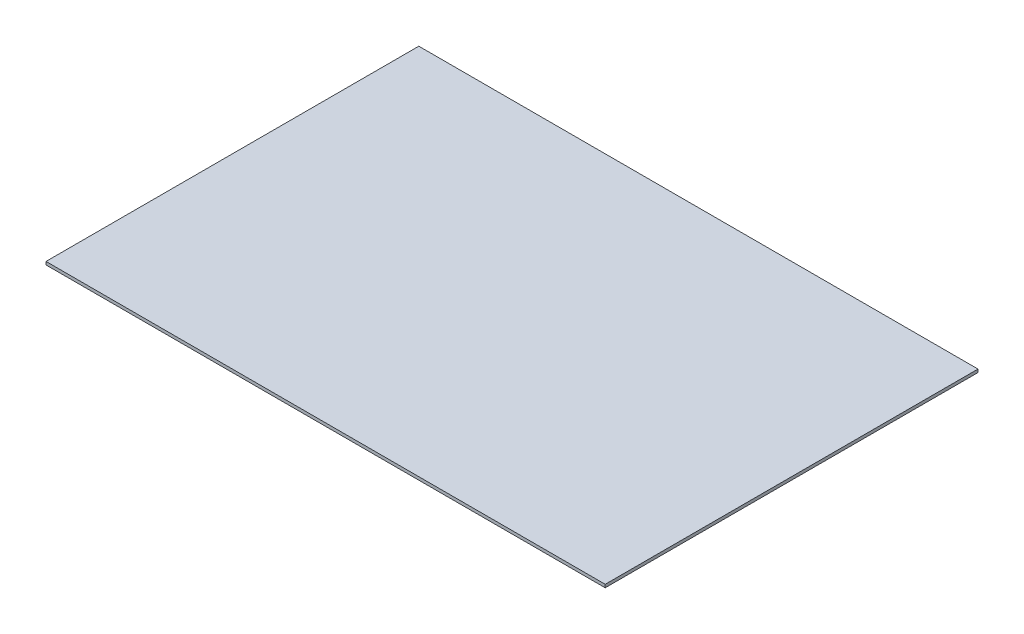
from build123d import *

# Parameters (mm, degrees)
SKETCH_1_W      = 1828.8
SKETCH_1_H      = 1219.2
EXTRUDE_1_DEPTH = 10


with BuildPart() as part:
    # Эскиз1 → Бобышка-Вытянуть1 (new body)
    with BuildSketch(Plane(origin=(0, 0, 0), x_dir=(1, 0, 0), z_dir=(0, 1, 0))):
        Rectangle(SKETCH_1_W, SKETCH_1_H)
    extrude(amount=EXTRUDE_1_DEPTH)


solid = part.part
